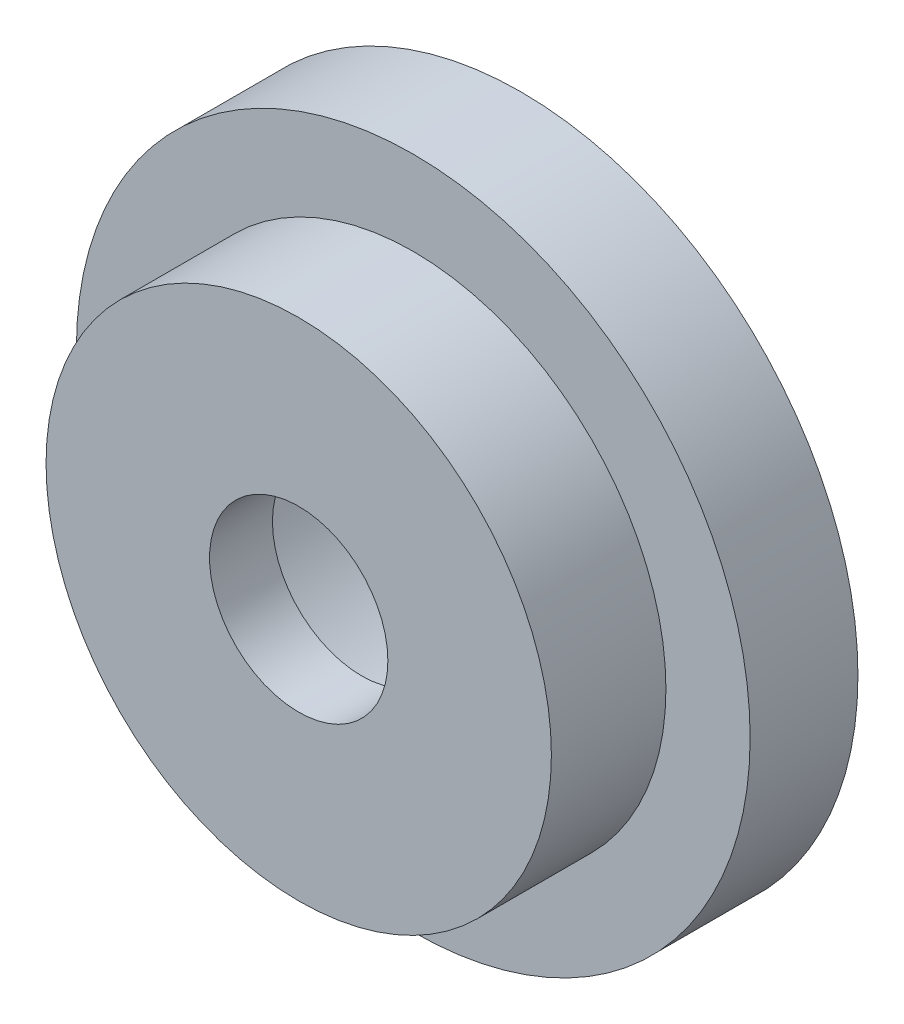
from build123d import *

# Parameters (mm, degrees)
F_3_8_CLEARANCE_HOLE1_D     = 10.0838
F_3_8_CLEARANCE_HOLE1_DEPTH = 15.621
SKETCH7_R                   = 11.1125
CUT_EXTRUDE2_DEPTH          = 12.065


with BuildPart() as part:
    # Sketch1 → Revolve1 (revolve)
    with BuildSketch(Plane(origin=(0, 0, 0), x_dir=(0, 0, -1), z_dir=(1, 0, 0))):
        Polygon((0, 0), (0, 14.2875), (6.477, 14.2875), (6.477, 19.05), (12.573, 19.05), (12.573, 14.2875), (15.621, 14.2875), (15.621, 0), align=None)
    revolve(axis=Axis((0, 0, 13.696708861), (0, 0, -1)))

    # 3/8 Clearance Hole1
    with Locations(Plane.XY):
        with Locations((0, 0)):
            Hole(F_3_8_CLEARANCE_HOLE1_D / 2, depth=F_3_8_CLEARANCE_HOLE1_DEPTH)

    # Sketch7 → Cut-Extrude2 (cut)
    with BuildSketch(Plane(origin=(0, 0, -15.621), x_dir=(-1, 0, 0), z_dir=(0, 0, -1))):
        Circle(SKETCH7_R)
    extrude(amount=-CUT_EXTRUDE2_DEPTH, mode=Mode.SUBTRACT)


solid = part.part
